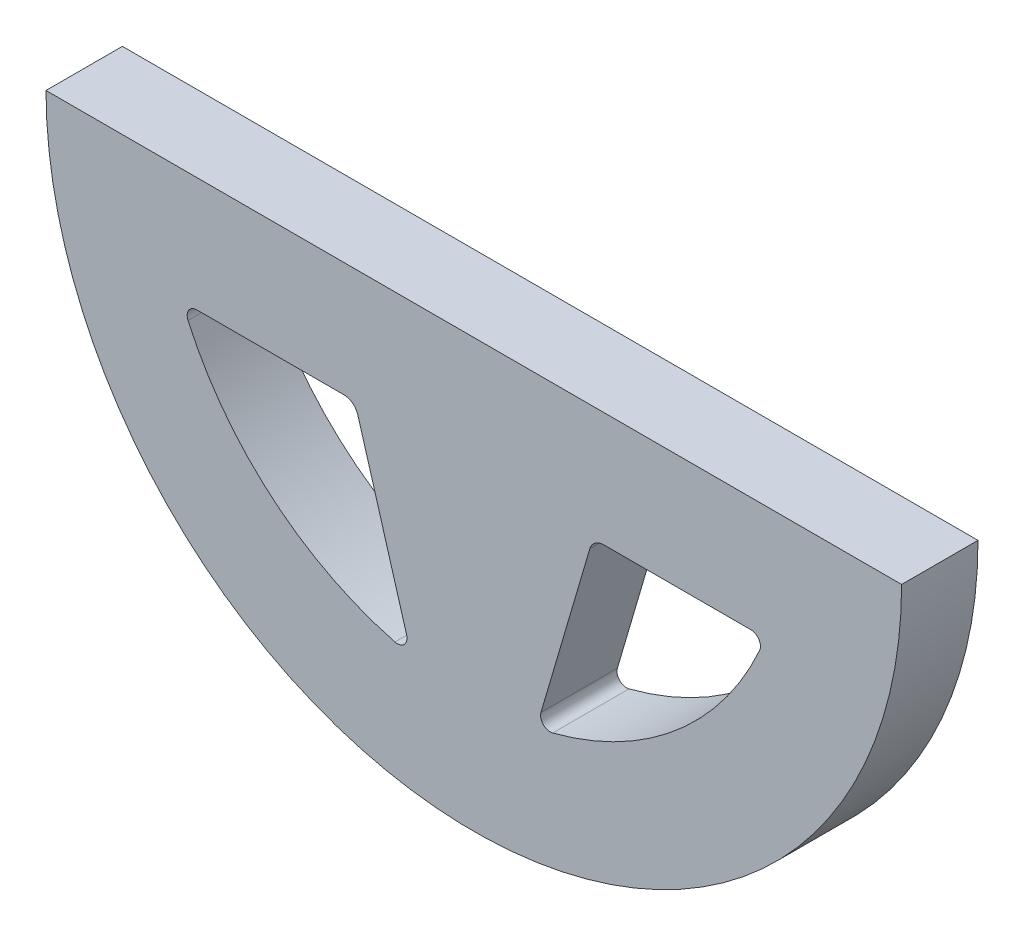
from build123d import *

# Parameters (mm, degrees)
BOSS_EXTRUDE1_DEPTH = 3.175
FILLET1_R           = 0.4
FILLET2_R           = 0.6


with BuildPart() as part:
    # Sketch1 → Boss-Extrude1 (new body)
    with BuildSketch(Plane.XY):
        with BuildLine():
            Line((-20.955, 0), (14.605, 0))
            ThreePointArc((14.605, 0), (-3.175, -17.78), (-20.955, 0))
        make_face()
        with BuildLine():
            Line((1.774264706, -4.7625), (8.940027858, -4.7625))
            ThreePointArc((8.940027858, -4.7625), (5.197167803, -9.968054601), (-0.576629116, -12.755538993))
            Line((-0.576629116, -12.755538993), (1.774264706, -4.7625))
        make_face(mode=Mode.SUBTRACT)
        with BuildLine():
            Line((-15.290027858, -4.7625), (-8.124264706, -4.7625))
            Line((-8.124264706, -4.7625), (-5.773370884, -12.755538993))
            ThreePointArc((-5.773370884, -12.755538993), (-11.547167803, -9.968054601), (-15.290027858, -4.7625))
        make_face(mode=Mode.SUBTRACT)
    extrude(amount=BOSS_EXTRUDE1_DEPTH)

    # Fillet1
    fillet1_edges = [part.edges().sort_by_distance(p)[0] for p in [
        (-5.773370884, -12.755538993, 1.5875),
        (-0.576629116, -12.755538993, 1.5875),
        (8.940027858, -4.7625, 1.5875),
        (-15.290027858, -4.7625, 1.5875),
    ]]
    fillet(fillet1_edges, radius=FILLET1_R)

    # Fillet2
    fillet2_edges = [part.edges().sort_by_distance(p)[0] for p in [
        (-8.124264706, -4.7625, 1.5875),
        (1.774264706, -4.7625, 1.5875),
    ]]
    fillet(fillet2_edges, radius=FILLET2_R)


solid = part.part
